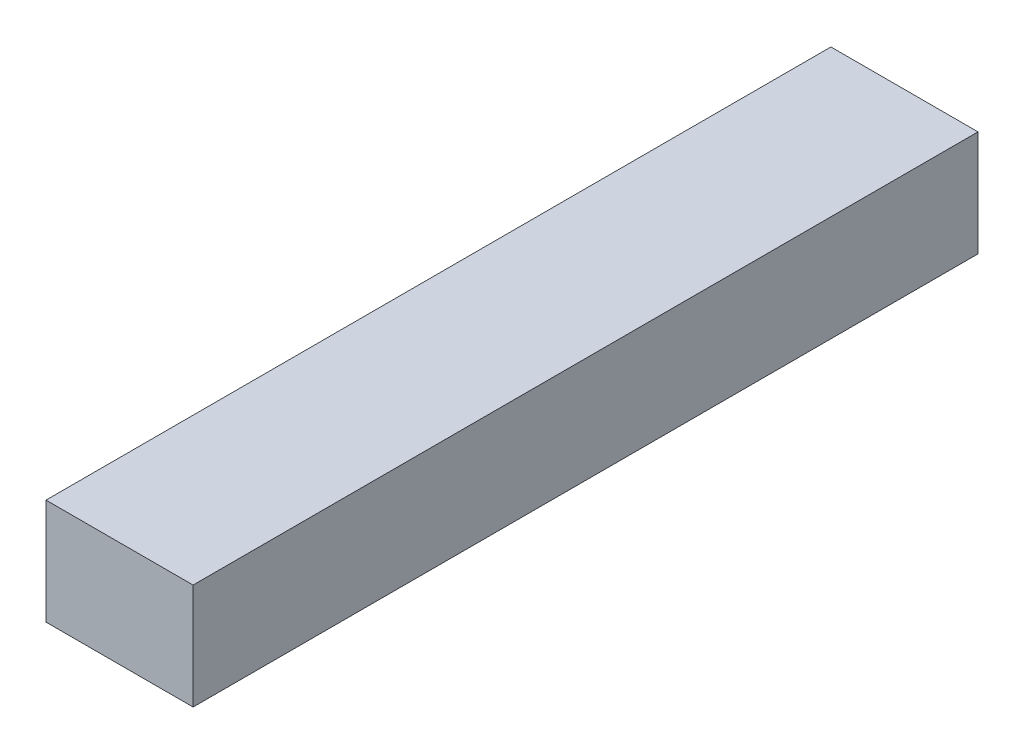
from build123d import *

# Parameters (mm, degrees)
SKETCH1_W           = 4.76
SKETCH1_H           = 3.42
BOSS_EXTRUDE1_DEPTH = 25.4


with BuildPart() as part:
    # Sketch1 → Boss-Extrude1 (new body)
    with BuildSketch(Plane.XY):
        Rectangle(SKETCH1_W, SKETCH1_H)
    extrude(amount=BOSS_EXTRUDE1_DEPTH)


solid = part.part
